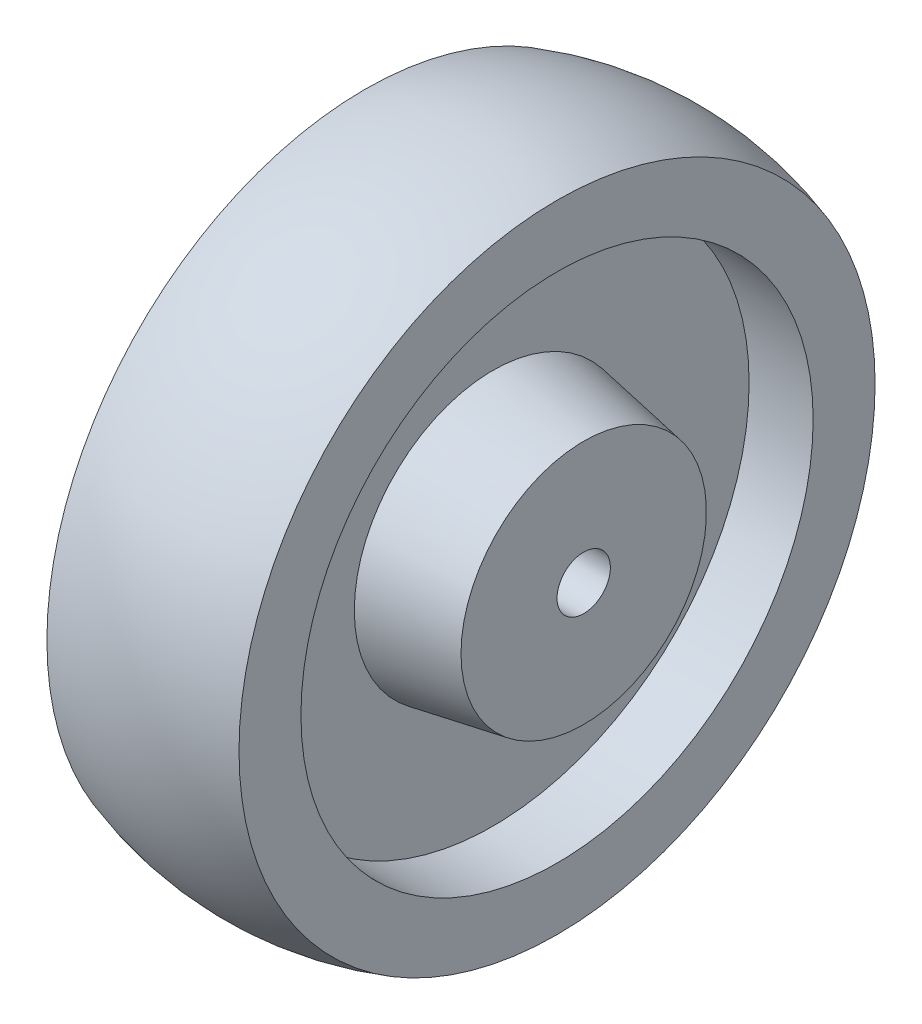
from build123d import *


with BuildPart() as part:
    # Sketch1 → Revolve1 (revolve)
    with BuildSketch(Plane.XY):
        with BuildLine():
            Line((-23, 5), (23, 5))
            Line((23, 5), (23, 23))
            Line((23, 23), (6, 26))
            Line((6, 26), (6, 48))
            Line((6, 48), (18, 48))
            Line((18, 48), (18, 59.609980773))
            ThreePointArc((18, 59.609980773), (0, 62.5), (-18, 59.609980773))
            Line((-18, 59.609980773), (-18, 48))
            Line((-18, 48), (-6, 48))
            Line((-6, 48), (-6, 26))
            Line((-6, 26), (-23, 23))
            Line((-23, 23), (-23, 5))
        make_face()
    revolve(axis=Axis((0, 0, 0), (1, 0, 0)))


solid = part.part
